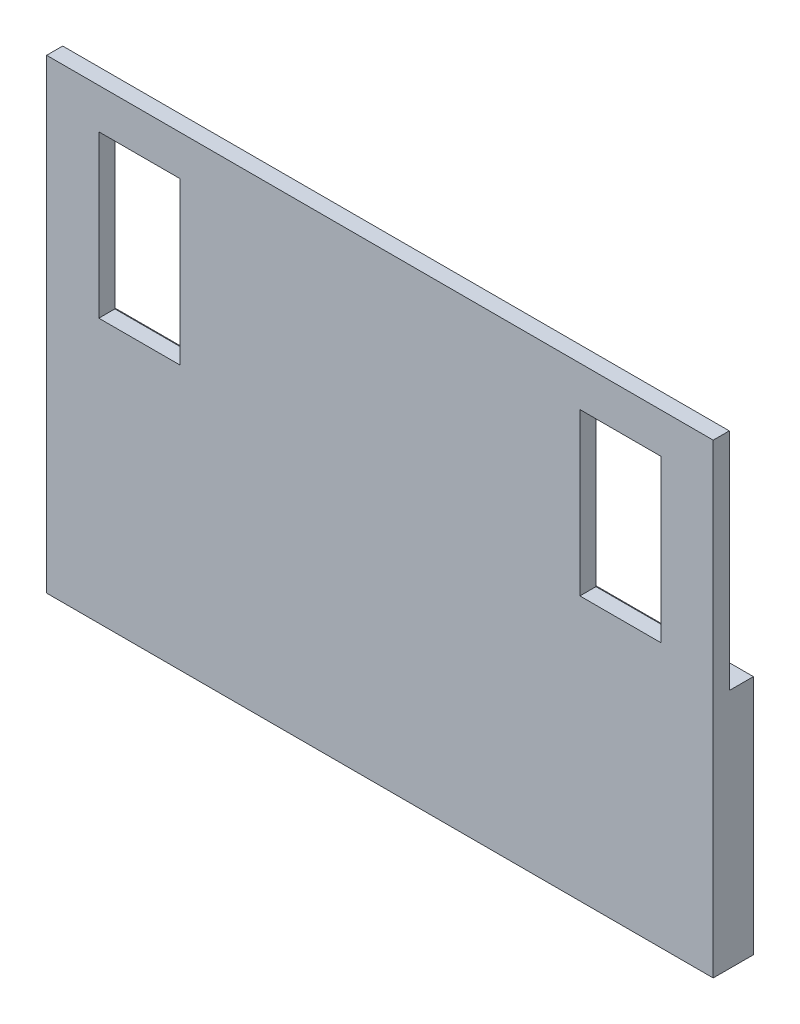
from build123d import *

# Parameters (mm, degrees)
SKETCH_1_W      = 83
SKETCH_1_H      = 58
SKETCH_1_W_2    = 10.1
SKETCH_1_H_2    = 20.1
EXTRUDE_1_DEPTH = 2
SKETCH_2_W      = 83
SKETCH_2_H      = 30
EXTRUDE_2_DEPTH = 3


with BuildPart() as part:
    # 草图1 → 凸台-拉伸1 (new body)
    with BuildSketch(Plane.XY):
        with Locations((-26.149980732, -49.330690158)):
            Rectangle(SKETCH_1_W, SKETCH_1_H)
        with Locations((3.800019268, -35.380690158)):
            Rectangle(SKETCH_1_W_2, SKETCH_1_H_2, mode=Mode.SUBTRACT)
        with Locations((-56.099980732, -35.380690158)):
            Rectangle(SKETCH_1_W_2, SKETCH_1_H_2, mode=Mode.SUBTRACT)
    extrude(amount=EXTRUDE_1_DEPTH)

    # 草图2 → 凸台-拉伸2 (add)
    with BuildSketch(Plane(origin=(0, 0, 0), x_dir=(-1, 0, 0), z_dir=(0, 0, -1))):
        with Locations((26.149980732, -63.330690158)):
            Rectangle(SKETCH_2_W, SKETCH_2_H)
    extrude(amount=EXTRUDE_2_DEPTH)


solid = part.part
